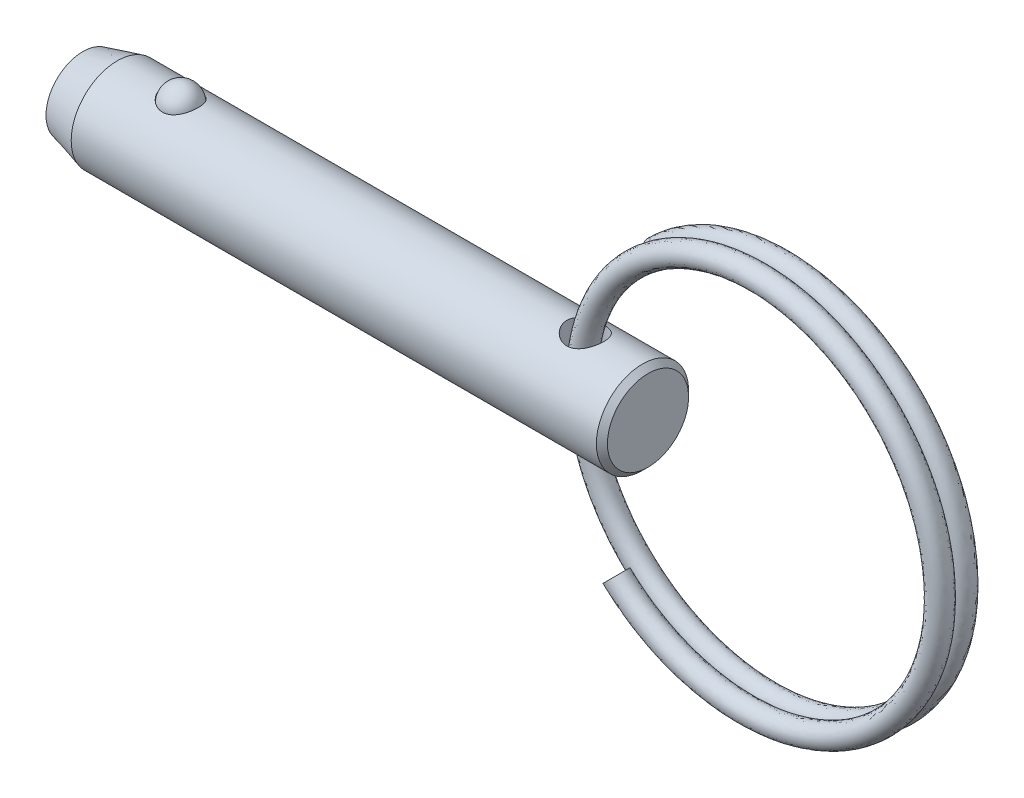
from build123d import *

# Parameters (mm, degrees)
SKETCH4_W          = 1.27
SKETCH4_H          = 6.35
SWEEP1_PITCH       = 1.5494
SWEEP1_HEIGHT      = 1.355725
SWEEP1_RADIUS      = 13.462
SKETCH6_R          = 0.762
SWEEP2_PITCH       = 1.5494
SWEEP2_HEIGHT      = 1.355725
SWEEP2_RADIUS      = 13.462
SWEEP2_START_ANGLE = -180
SKETCH6_2_R        = 0.762


with BuildPart() as part:
    # Sketch1 → Revolve1 (revolve)
    with BuildSketch(Plane.XY):
        Polygon((19.4564, 2.794), (19.0754, 3.175), (-17.086547737, 3.175), (-19.4564, 2.54), (-19.4564, 0), (19.4564, 0), align=None)
    revolve(axis=Axis((19.4564, 0, 0), (1, 0, 0)))

    # Sketch2 → Cut-Revolve1 (revolve, cut)
    with BuildSketch(Plane.XY):
        with BuildLine():
            Line((-11.464582051, 2.8575), (-13.979182051, 2.8575))
            ThreePointArc((-13.979182051, 2.8575), (-12.721882051, 4.1148), (-11.464582051, 2.8575))
        make_face()
    revolve(axis=Axis((-11.464582051, 2.8575, 0), (1, 0, 0)), mode=Mode.SUBTRACT)

    # Sketch4 → Cut-Revolve2 (revolve, cut)
    with BuildSketch(Plane.XY):
        with Locations((15.7734, 0)):
            Rectangle(SKETCH4_W, SKETCH4_H)
    revolve(axis=Axis((15.1384, -3.175, 0), (0, 1, 0)), mode=Mode.SUBTRACT)


with BuildPart() as body_2:
    # Sketch3 → Revolve2 (revolve)
    with BuildSketch(Plane.XY):
        with BuildLine():
            Line((-11.489982051, 2.8575), (-13.953782051, 2.8575))
            ThreePointArc((-13.953782051, 2.8575), (-12.721882051, 4.0894), (-11.489982051, 2.8575))
        make_face()
    revolve(axis=Axis((-11.489982051, 2.8575, 0), (1, 0, 0)))


with BuildPart() as body_3:
    # Sweep1: sweep along a helix
    with BuildLine() as sweep1_path:
        Helix(SWEEP1_PITCH, SWEEP1_HEIGHT, SWEEP1_RADIUS, center=(27.623425091, 0, 0), direction=(0, 0, -1), lefthand=True)
    # Sketch6 → Sweep1 (sweep)
    with BuildSketch(Plane(origin=(114.003847968, 0, 0), x_dir=(0, 0, -1), z_dir=(0, 1, 0))):
        with Locations((0, 99.080422877)):
            Circle(SKETCH6_R)
    sweep(path=sweep1_path.line, is_frenet=True)

    # Sweep2: sweep along a helix
    with BuildLine() as sweep2_path:
        add(Helix(SWEEP2_PITCH, SWEEP2_HEIGHT, SWEEP2_RADIUS, center=(27.623425091, 0, 0), direction=(0, 0, 1), lefthand=True, mode=Mode.PRIVATE).rotate(Axis((27.623425091, 0, 0), (0, 0, 1)), SWEEP2_START_ANGLE))
    # Sketch6_2 → Sweep2 (sweep)
    with BuildSketch(Plane(origin=(114.003847968, 0, 0), x_dir=(0, 0, -1), z_dir=(0, 1, 0))):
        with Locations((0, 99.080422877)):
            Circle(SKETCH6_2_R)
    sweep(path=sweep2_path.line, is_frenet=True)


solid = Compound([part.part, body_2.part, body_3.part])
